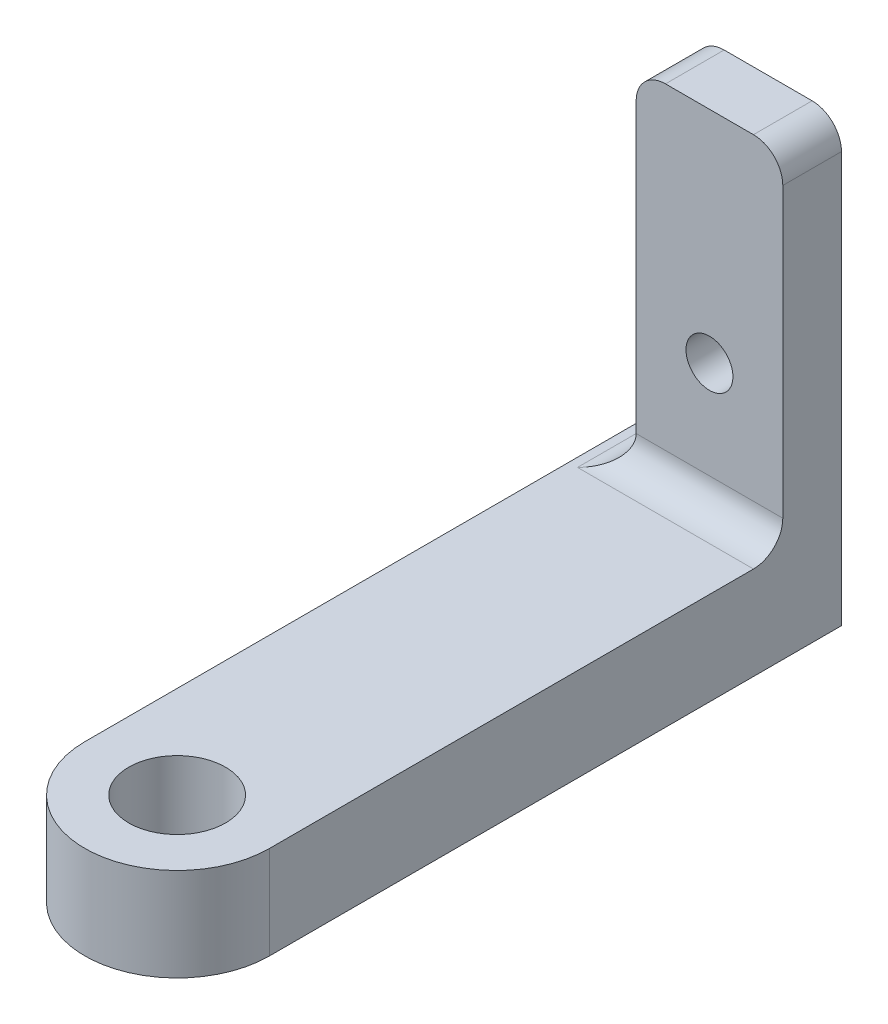
from build123d import *

# Parameters (mm, degrees)
SKETCH1_R           = 6.3
SKETCH1_R_2         = 3.3
BOSS_EXTRUDE1_DEPTH = 6.35
SKETCH2_W           = 10
SKETCH2_H           = 30
SKETCH2_R           = 1.6
BOSS_EXTRUDE2_DEPTH = 4
FILLET1_R           = 2


with BuildPart() as part:
    # Sketch1 → Boss-Extrude1 (new body)
    with BuildSketch(Plane(origin=(0, 0, 0), x_dir=(1, 0, 0), z_dir=(0, 1, 0))):
        Circle(SKETCH1_R)
        Circle(SKETCH1_R_2, mode=Mode.SUBTRACT)
        with BuildLine():
            Line((-6.3, 39), (-6.3, 0))
            ThreePointArc((-6.3, 0), (0, 6.3), (6.3, 0))
            Line((6.3, 0), (6.3, 39))
            Line((6.3, 39), (-6.3, 39))
        make_face()
    extrude(amount=BOSS_EXTRUDE1_DEPTH)

    # Sketch2 → Boss-Extrude2 (add)
    with BuildSketch(Plane(origin=(0, 0, -39), x_dir=(-1, 0, 0), z_dir=(0, 0, -1))):
        with Locations((-1.3, 15)):
            Rectangle(SKETCH2_W, SKETCH2_H)
        with Locations((-1.3, 15)):
            Circle(SKETCH2_R, mode=Mode.SUBTRACT)
    extrude(amount=-BOSS_EXTRUDE2_DEPTH)

    # Fillet1
    fillet1_edges = [part.edges().sort_by_distance(p)[0] for p in [
        (6.3, 30, -37),
        (-3.7, 6.35, -37),
        (-3.7, 30, -37),
        (1.3, 6.35, -35),
    ]]
    fillet(fillet1_edges, radius=FILLET1_R)


solid = part.part
